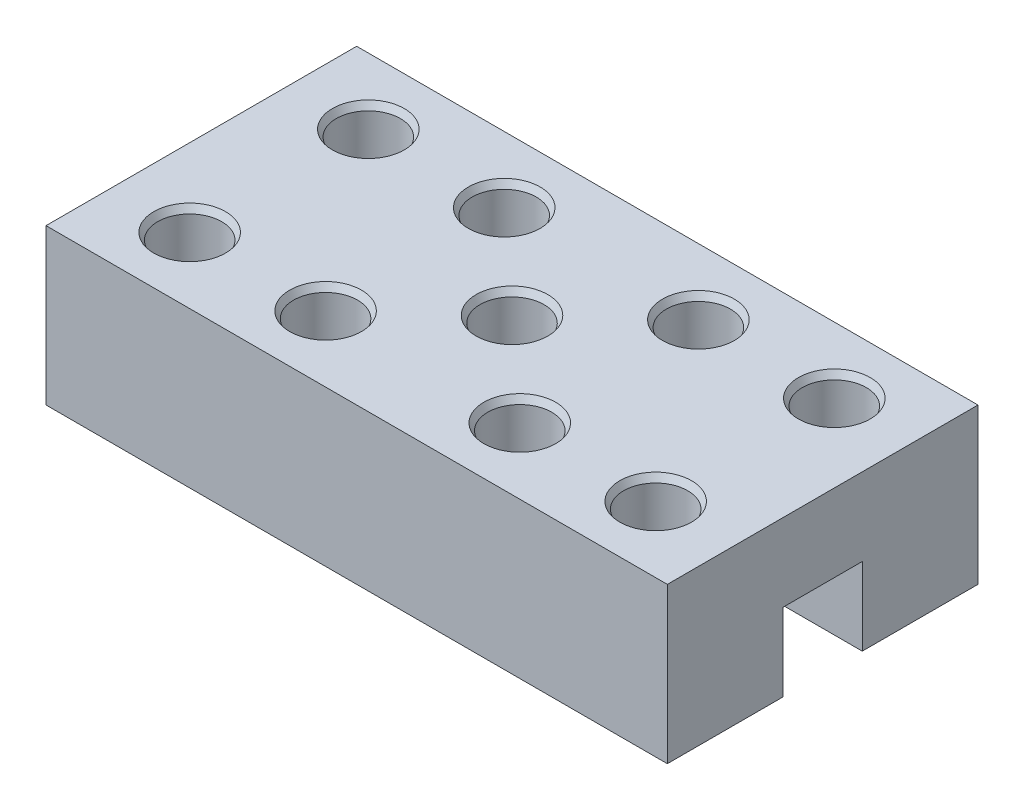
from build123d import *

# Parameters (mm, degrees)
SKETCH1_W           = 80
SKETCH1_H           = 40
BOSS_EXTRUDE1_DEPTH = 20
SKETCH2_W           = 10.2
SKETCH2_H           = 20
CUT_EXTRUDE1_DEPTH  = 81
SKETCH3_R           = 4.125
CUT_EXTRUDE2_DEPTH  = 21
CHAMFER1_SIZE       = 0.5
CHAMFER1_SIZE2      = 0.866025404


with BuildPart() as part:
    # Sketch1 → Boss-Extrude1 (new body)
    with BuildSketch(Plane(origin=(0, 0, 0), x_dir=(1, 0, 0), z_dir=(0, 1, 0))):
        Rectangle(SKETCH1_W, SKETCH1_H)
    extrude(amount=BOSS_EXTRUDE1_DEPTH)

    # Sketch2 → Cut-Extrude1 (cut, through all)
    with BuildSketch(Plane.ZY.offset(40)):
        Rectangle(SKETCH2_W, SKETCH2_H)
    extrude(amount=-CUT_EXTRUDE1_DEPTH, mode=Mode.SUBTRACT)

    # Sketch3 → Cut-Extrude2 (cut, through all)
    with BuildSketch(Plane(origin=(0, 20, 0), x_dir=(1, 0, 0), z_dir=(0, 1, 0))):
        with Locations(Location((12.5, -11.5, 0), (0, 0, 270))):  # turned: the seam where the file's is
            Circle(SKETCH3_R)
        with Locations(Location((-12.5, -11.5, 0), (0, 0, 270))):  # turned: the seam where the file's is
            Circle(SKETCH3_R)
        with Locations(Location((-12.5, 11.5, 0), (0, 0, 270))):  # turned: the seam where the file's is
            Circle(SKETCH3_R)
        with Locations(Location((12.5, 11.5, 0), (0, 0, 270))):  # turned: the seam where the file's is
            Circle(SKETCH3_R)
        with Locations(Location((30, -11.5, 0), (0, 0, 270))):  # turned: the seam where the file's is
            Circle(SKETCH3_R)
        with Locations(Location((-30, -11.5, 0), (0, 0, 270))):  # turned: the seam where the file's is
            Circle(SKETCH3_R)
        with Locations(Location((-30, 11.5, 0), (0, 0, 270))):  # turned: the seam where the file's is
            Circle(SKETCH3_R)
        with Locations(Location((30, 11.5, 0), (0, 0, 270))):  # turned: the seam where the file's is
            Circle(SKETCH3_R)
        with Locations(Location((0, 0, 0), (0, 0, 270))):  # turned: the seam where the file's is
            Circle(SKETCH3_R)
    extrude(amount=-CUT_EXTRUDE2_DEPTH, mode=Mode.SUBTRACT)

    # Chamfer1
    chamfer1_edges = [part.edges().sort_by_distance(p)[0] for p in [
        (12.5, 20, 7.375),
        (0, 20, -4.125),
        (30, 20, -15.625),
        (-30, 20, -15.625),
        (-30, 20, 7.375),
        (30, 20, 7.375),
        (12.5, 20, -15.625),
        (-12.5, 20, -15.625),
        (-12.5, 20, 7.375),
    ]]
    chamfer1_side = [part.faces().sort_by_distance(p)[0] for p in [
        (0, 20, 19.105572809),
    ]]
    chamfer(chamfer1_edges, length=CHAMFER1_SIZE, length2=CHAMFER1_SIZE2, reference=chamfer1_side[0])


solid = part.part
